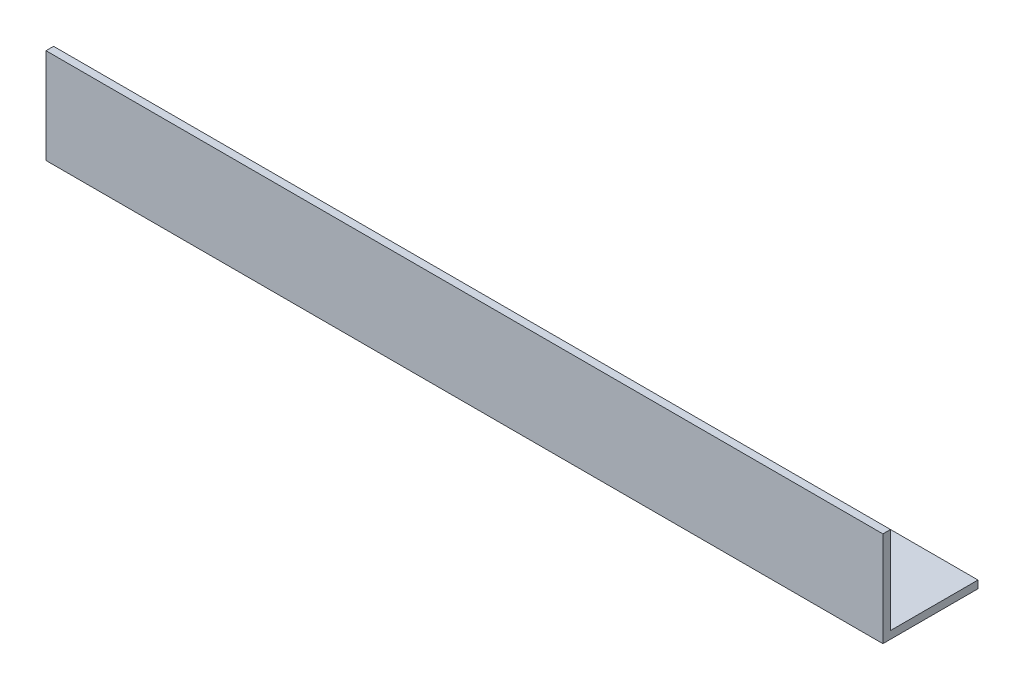
from build123d import *

# Parameters (mm, degrees)
EXTRUDE_1_DEPTH     = 220
CUT_EXTRUDE_1_DEPTH = 26


with BuildPart() as part:
    # Эскиз1 → Вытянуть-Тонкостенный1 (new body)
    with BuildSketch(Plane(origin=(0, 0, 0), x_dir=(0, 0, -1), z_dir=(1, 0, 0))):
        Polygon((0, 25), (0, 0), (25, 0), (25, 2), (2, 2), (2, 25), align=None)
    extrude(amount=EXTRUDE_1_DEPTH)

    # Эскиз3 → Вырез-Вытянуть1 (cut, through all)
    with BuildSketch(Plane.XZ):
        Polygon((0, -25), (14.444982857, -18.190263819), (31.898443386, -25), align=None)
        Polygon((40, -25), (54.444982857, -18.190263819), (71.898443386, -25), align=None)
        Polygon((80, -25), (94.444982857, -18.190263819), (111.898443386, -25), align=None)
        Polygon((120, -25), (134.444982857, -18.190263819), (151.898443386, -25), align=None)
        Polygon((160, -25), (174.444982857, -18.190263819), (191.898443386, -25), align=None)
    extrude(amount=-CUT_EXTRUDE_1_DEPTH, mode=Mode.SUBTRACT)


solid = part.part
